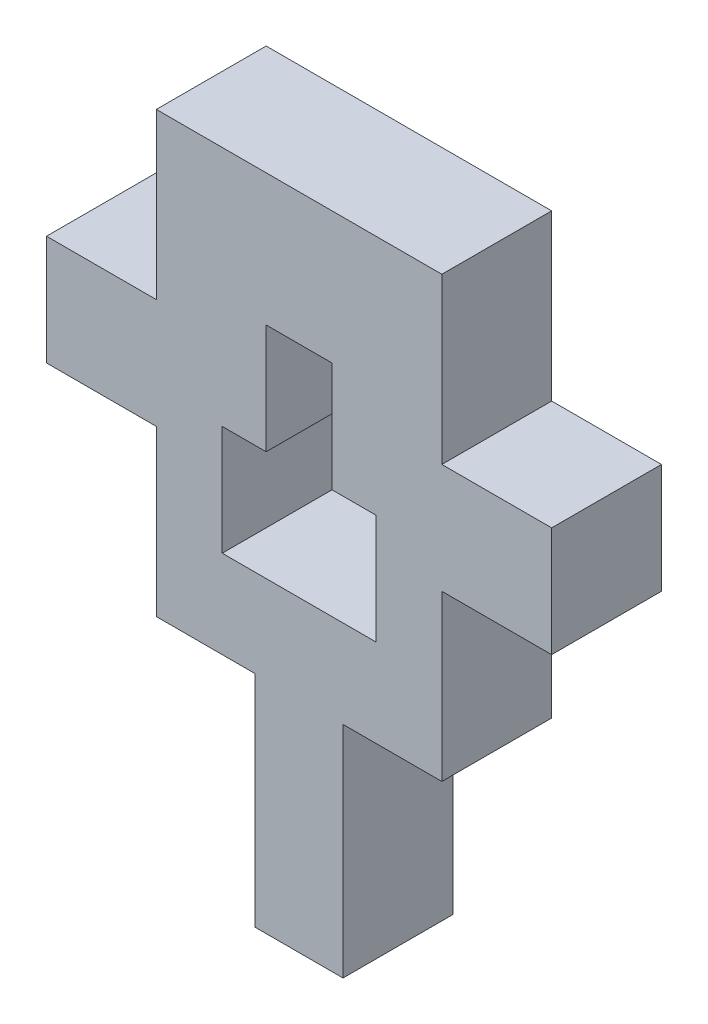
from build123d import *

# Parameters (mm, degrees)
ESQUISSE1_W             = 4
ESQUISSE1_H             = 10
ESQUISSE1_W_2           = 5
ESQUISSE1_H_2           = 5
ESQUISSE1_W_3           = 13
ESQUISSE1_H_3           = 20
BOSS_EXTRU_1_DEPTH      = 5
ESQUISSE2_W             = 7
ESQUISSE2_H             = 5
ENL_V_MAT_EXTRU_1_DEPTH = 10
ESQUISSE3_W             = 3
ESQUISSE3_H             = 10
ENL_V_MAT_EXTRU_2_DEPTH = 10


with BuildPart() as part:
    # Esquisse1 → Boss.-Extru.1 (new body)
    with BuildSketch(Plane.XY):
        with Locations((6.5, -5)):
            Rectangle(ESQUISSE1_W, ESQUISSE1_H)
        with Locations((-2.5, 10)):
            Rectangle(ESQUISSE1_W_2, ESQUISSE1_H_2)
        with Locations((6.5, 10)):
            Rectangle(ESQUISSE1_W_3, ESQUISSE1_H_3)
        with Locations((15.5, 10)):
            Rectangle(ESQUISSE1_W_2, ESQUISSE1_H_2)
    extrude(amount=BOSS_EXTRU_1_DEPTH)

    # Esquisse2 → Enlèv. mat.-Extru.1 (cut)
    with BuildSketch(Plane(origin=(0, 0, 0), x_dir=(-1, 0, 0), z_dir=(0, 0, -1))):
        with Locations((-6.5, 6.5)):
            Rectangle(ESQUISSE2_W, ESQUISSE2_H)
    extrude(amount=-ENL_V_MAT_EXTRU_1_DEPTH, mode=Mode.SUBTRACT)

    # Esquisse3 → Enlèv. mat.-Extru.2 (cut)
    with BuildSketch(Plane(origin=(0, 0, 0), x_dir=(-1, 0, 0), z_dir=(0, 0, -1))):
        with Locations((-6.5, 9)):
            Rectangle(ESQUISSE3_W, ESQUISSE3_H)
    extrude(amount=-ENL_V_MAT_EXTRU_2_DEPTH, mode=Mode.SUBTRACT)


solid = part.part
